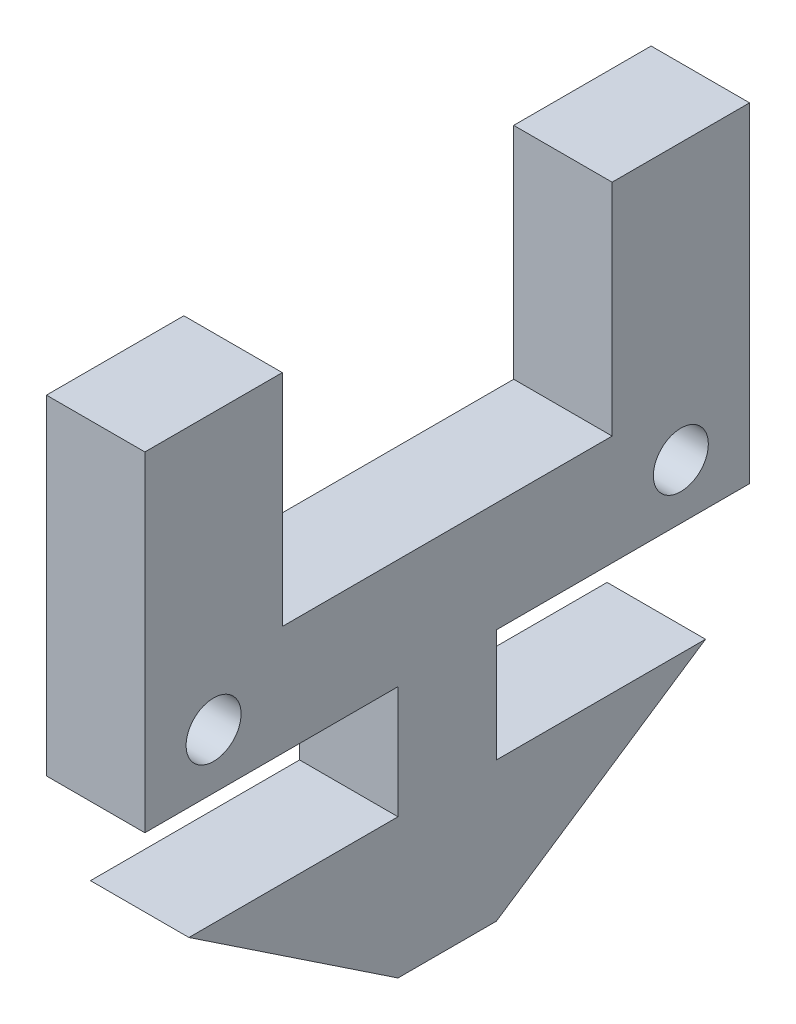
from build123d import *

# Parameters (mm, degrees)
BOSS_EXTRUDE1_DEPTH = 3.5814
SKETCH7_R           = 1
CUT_EXTRUDE5_DEPTH  = 4.5814
BOSS_EXTRUDE3_DEPTH = 3.5814


with BuildPart() as part:
    # Sketch1 → Boss-Extrude1 (new body)
    with BuildSketch(Plane(origin=(0, 0, 0), x_dir=(0, 0, -1), z_dir=(1, 0, 0))):
        Polygon((-6, 6), (-6, -2), (6, -2), (6, 6), (11, 6), (11, -6), (-11, -6), (-11, 6), align=None)
    extrude(amount=BOSS_EXTRUDE1_DEPTH)

    # Sketch7 → Cut-Extrude5 (cut, through all)
    with BuildSketch(Plane(origin=(3.5814, 0, 0), x_dir=(0, 0, -1), z_dir=(1, 0, 0))):
        with Locations((-8.5, -4)):
            Circle(SKETCH7_R)
        with Locations((8.5, -4)):
            Circle(SKETCH7_R)
    extrude(amount=-CUT_EXTRUDE5_DEPTH, mode=Mode.SUBTRACT)

    # Sketch8 → Boss-Extrude3 (add)
    with BuildSketch(Plane(origin=(0, 0, 0), x_dir=(0, 0, -1), z_dir=(1, 0, 0))):
        Polygon((-1.7907, -10.1), (-9.398, -10.1), (-1.7907, -15.18), (1.7907, -15.18), (9.398, -10.1), (1.7907, -10.1), (1.7907, -6), (-1.7907, -6), align=None)
    extrude(amount=BOSS_EXTRUDE3_DEPTH)


solid = part.part
